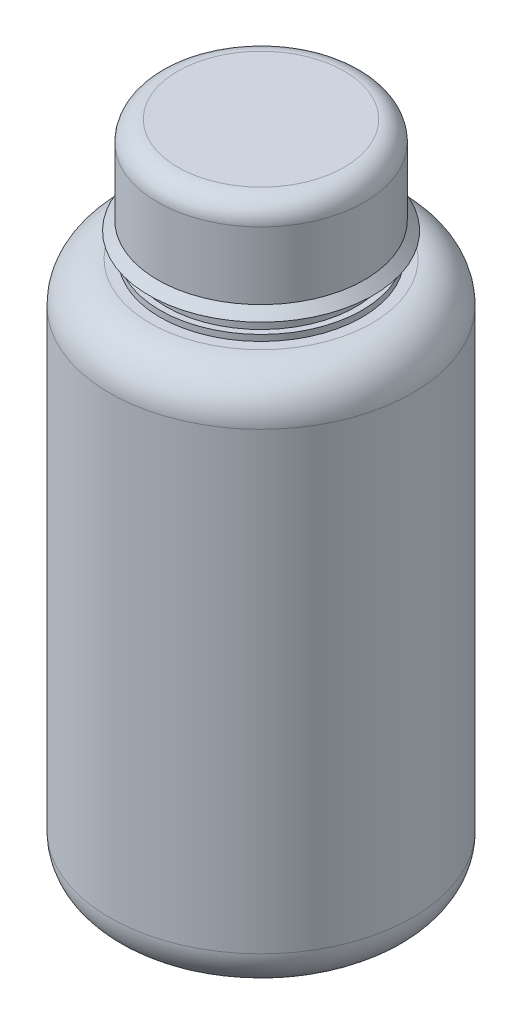
from build123d import *


with BuildPart() as part:
    # Sketch4 → Revolve1 (revolve)
    with BuildSketch(Plane(origin=(0, 0, 0), x_dir=(0, 0, -1), z_dir=(1, 0, 0))):
        with BuildLine():
            Line((0, 0), (-34.925, 0))
            ThreePointArc((-34.925, 0), (-43.905256121, 3.719743879), (-47.625, 12.7))
            Line((-47.625, 12.7), (-47.625, 155.575))
            ThreePointArc((-47.625, 155.575), (-43.905256121, 164.555256121), (-34.925, 168.275))
            Line((-34.925, 168.275), (-31.75, 168.275))
            Line((-31.75, 168.275), (-31.75, 170.188405715))
            Line((-31.75, 170.188405715), (-29.850831966, 170.188405715))
            Line((-29.850831966, 170.188405715), (-29.850831966, 174.113488189))
            Line((-29.850831966, 174.113488189), (-31.75, 174.113488189))
            Line((-31.75, 174.113488189), (-31.75, 176.015383727))
            Line((-31.75, 176.015383727), (-35.259086236, 176.015383727))
            Line((-35.259086236, 176.015383727), (-32.54375, 178.87031185))
            Line((-32.54375, 178.87031185), (-32.54375, 200.025))
            ThreePointArc((-32.54375, 200.025), (-30.683878061, 204.515128061), (-26.19375, 206.375))
            Line((-26.19375, 206.375), (0, 206.375))
            Line((0, 206.375), (0, 0))
        make_face()
    revolve(axis=Axis((0, -30.534688995, 0), (0, 1, 0)))


solid = part.part
